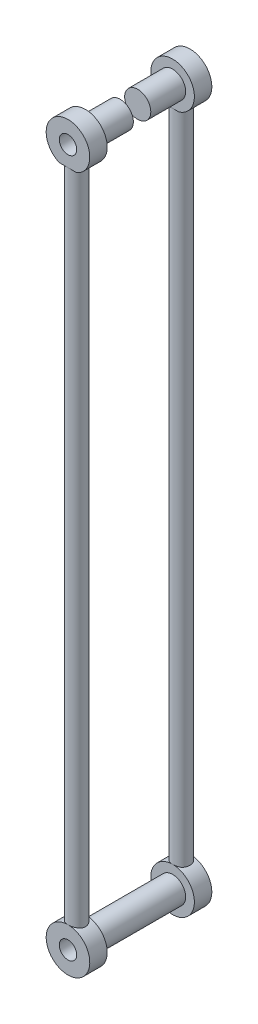
from build123d import *
from build123d.topology import SkipClean

# Parameters (mm, degrees)
SKETCH1_R               = 12.5
SKETCH1_R_2             = 5
BOSS_EXTRUDE1_DEPTH     = 10
CUT_EXTRUDE2_DEPTH      = 21.310096012
SKETCH3_R               = 5
BOSS_EXTRUDE2_DEPTH     = 188
SKETCH5_R               = 12.5
SKETCH5_R_2             = 5
BOSS_EXTRUDE4_DEPTH     = 10
SKETCH7_R               = 7.5
BOSS_EXTRUDE5_DEPTH     = 50
BOSS_EXTRUDE5_2_DEPTH   = 50
SKETCH8_R               = 12.5
SKETCH8_R_2             = 5
BOSS_EXTRUDE6_DEPTH     = 10
BOSS_EXTRUDE6_2_DEPTH   = 10
CUT_EXTRUDE3_DEPTH      = 20
SKETCH10_R              = 5
BOSS_EXTRUDE7_DEPTH     = 380
SKETCH11_W              = 10
SKETCH11_H              = 26.37697812
CUT_EXTRUDE5_DEPTH      = 419.583922409
CUT_EXTRUDE5_DEPTH_BACK = 419.583922409


with BuildPart() as part:
    # Sketch1 → Boss-Extrude1 (new body)
    with BuildSketch(Plane.XY):
        Circle(SKETCH1_R)
        Circle(SKETCH1_R_2, mode=Mode.SUBTRACT)
    extrude(amount=BOSS_EXTRUDE1_DEPTH)

    # Sketch2 → Cut-Extrude2 (cut, through all)
    with BuildSketch(Plane.XY.offset(10)):
        with BuildLine():
            Line((9.108105184, -12), (3.5, -12))
            ThreePointArc((3.5, -12), (0, -12.5), (-3.5, -12))
            Line((-3.5, -12), (-7.494861462, -12))
            Line((-7.494861462, -12), (-7.494861462, -13.628548532))
            Line((-7.494861462, -13.628548532), (9.511416115, -13.628548532))
            Line((9.511416115, -13.628548532), (9.108105184, -12))
        make_face()
        with BuildLine():
            Line((3.5, -12), (0, -12))
            Line((0, -12), (-3.5, -12))
            ThreePointArc((-3.5, -12), (0, -12.5), (3.5, -12))
        make_face()
    extrude(amount=-CUT_EXTRUDE2_DEPTH, mode=Mode.SUBTRACT)

    # Sketch3 → Boss-Extrude2 (add)
    with BuildSketch(Plane(origin=(0, -12, 0), x_dir=(-1, 0, 0), z_dir=(0, -1, 0))):
        with Locations(Location((0, -5, 0), (0, 0, 90))):
            Circle(SKETCH3_R)
    boss_extrude2 = extrude(amount=BOSS_EXTRUDE2_DEPTH)

    # Mirror2: Boss-Extrude2 across plane
    add(boss_extrude2.mirror(Plane(origin=(0, -200, 5), x_dir=(0, 0, 1), z_dir=(0, -1, 0))))

    # Sketch5 → Boss-Extrude4 (add)
    with SkipClean():  # the faces are left unmerged after this step: merging them gives an invalid solid
        with BuildSketch(Plane.XY):
            with Locations((0, -400)):
                Circle(SKETCH5_R)
            with Locations((0, -400)):
                Circle(SKETCH5_R_2, mode=Mode.SUBTRACT)
        extrude(amount=BOSS_EXTRUDE4_DEPTH)


with BuildPart() as body_2:
    # Sketch7 → Boss-Extrude5 (new body)
    with BuildSketch(Plane.XY.offset(10)):
        Circle(SKETCH7_R)
    extrude(amount=BOSS_EXTRUDE5_DEPTH)

    # Sketch11 → Cut-Extrude5 (cut, two sides)
    with BuildSketch(Plane(origin=(0, 0, 0), x_dir=(0, 0, -1), z_dir=(1, 0, 0))) as cut_extrude5_sk:
        with Locations((-35, -5.68848906)):
            Rectangle(SKETCH11_W, SKETCH11_H)
    extrude(amount=CUT_EXTRUDE5_DEPTH, mode=Mode.SUBTRACT)
    extrude(cut_extrude5_sk.sketch, amount=-CUT_EXTRUDE5_DEPTH_BACK, mode=Mode.SUBTRACT)


with BuildPart() as body_3:
    # Sketch7 → Boss-Extrude5 2 (new body)
    with BuildSketch(Plane.XY.offset(10)):
        with Locations((0, -400)):
            Circle(SKETCH7_R)
    extrude(amount=BOSS_EXTRUDE5_2_DEPTH)


with BuildPart() as body_4:
    # Sketch8 → Boss-Extrude6 (new body)
    with BuildSketch(Plane.XY.offset(60)):
        Circle(SKETCH8_R)
        Circle(SKETCH8_R_2, mode=Mode.SUBTRACT)
    extrude(amount=BOSS_EXTRUDE6_DEPTH)

    # Sketch9 → Cut-Extrude3 (cut)
    with BuildSketch(Plane.XY.offset(70)):
        Polygon((-5, -12), (-5, -11.456439237), (5, -11.456439237), (5, -13.442017523), align=None)
    extrude(amount=-CUT_EXTRUDE3_DEPTH, mode=Mode.SUBTRACT)



with BuildPart() as body_5:
    # Sketch8 → Boss-Extrude6 2 (new body)
    with BuildSketch(Plane.XY.offset(60)):
        with Locations((0, -400)):
            Circle(SKETCH8_R)
        with Locations((0, -400)):
            Circle(SKETCH8_R_2, mode=Mode.SUBTRACT)
    extrude(amount=BOSS_EXTRUDE6_2_DEPTH)


with BuildPart() as body_4_1:
    with SkipClean():  # the faces are left unmerged after this step: merging them gives an invalid solid
        add(body_4.part)

        add(body_5.part)  # Boss-Extrude7 merges body 5
        # Sketch10 → Boss-Extrude7 (add)
        with BuildSketch(Plane(origin=(0, -11.456439237, 0), x_dir=(-1, 0, 0), z_dir=(0, -1, 0))):
            with Locations(Location((0, -65, 0), (0, 0, 270))):
                Circle(SKETCH10_R)
        extrude(amount=BOSS_EXTRUDE7_DEPTH)


with BuildPart() as cut_extrude5_piece_1:
    # of the separate pieces the step leaves, piece 1, a body of its own (cut_extrude5_pieces)
    add(body_2.part.solids().sort_by_distance((7.5, 0, 40))[0])


with BuildPart() as cut_extrude5_piece_2:
    # of the separate pieces the step leaves, piece 2, a body of its own (cut_extrude5_pieces)
    add(body_2.part.solids().sort_by_distance((7.5, 0, 10))[0])


solid = Compound([part.part, body_3.part, body_4_1.part, cut_extrude5_piece_1.part, cut_extrude5_piece_2.part])
